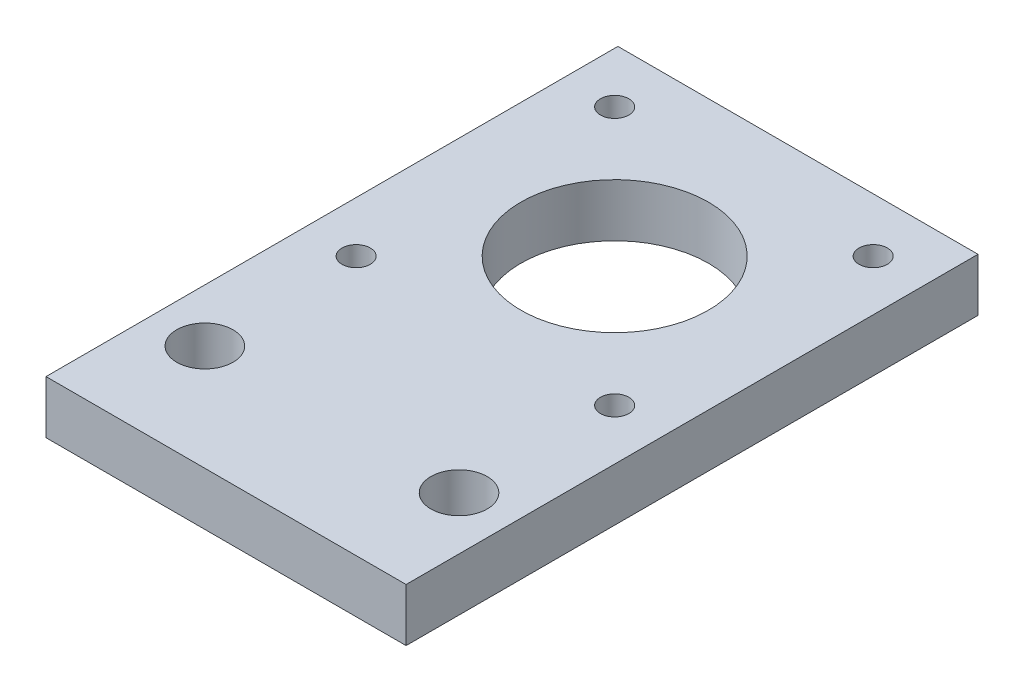
from build123d import *

# Parameters (mm, degrees)
SKETCH1_W               = 43.18
SKETCH1_H               = 68.58
BOSS_EXTRUDE1_DEPTH     = 6.35
F_1_4_CLEARANCE_HOLE1_D = 6.7564
SKETCH7_R               = 11.239
CUT_EXTRUDE1_DEPTH      = 7.35
M3_CLEARANCE_HOLE1_D    = 3.4


with BuildPart() as part:
    # Sketch1 → Boss-Extrude1 (new body)
    with BuildSketch(Plane(origin=(0, 0, 0), x_dir=(1, 0, 0), z_dir=(0, 1, 0))):
        Rectangle(SKETCH1_W, SKETCH1_H)
    extrude(amount=BOSS_EXTRUDE1_DEPTH)

    # 1/4 Clearance Hole1 (through all)
    with Locations(Plane(origin=(0, 6.35, 0), x_dir=(1, 0, 0), z_dir=(0, 1, 0))):
        with Locations((15.24, -21.59), (-15.24, -21.59)):
            Hole(F_1_4_CLEARANCE_HOLE1_D / 2)

    # Sketch7 → Cut-Extrude1 (cut, through all)
    with BuildSketch(Plane.XZ):
        with Locations((0, -12.31)):
            Circle(SKETCH7_R)
    extrude(amount=-CUT_EXTRUDE1_DEPTH, mode=Mode.SUBTRACT)

    # M3 Clearance Hole1 (through all)
    with Locations(Plane(origin=(0, 0, 0), x_dir=(-1, 0, 0), z_dir=(0, -1, 0))):
        with Locations((-15.5, 27.81), (15.5, 27.81), (15.5, -3.19), (-15.5, -3.19)):
            Hole(M3_CLEARANCE_HOLE1_D / 2)


solid = part.part
